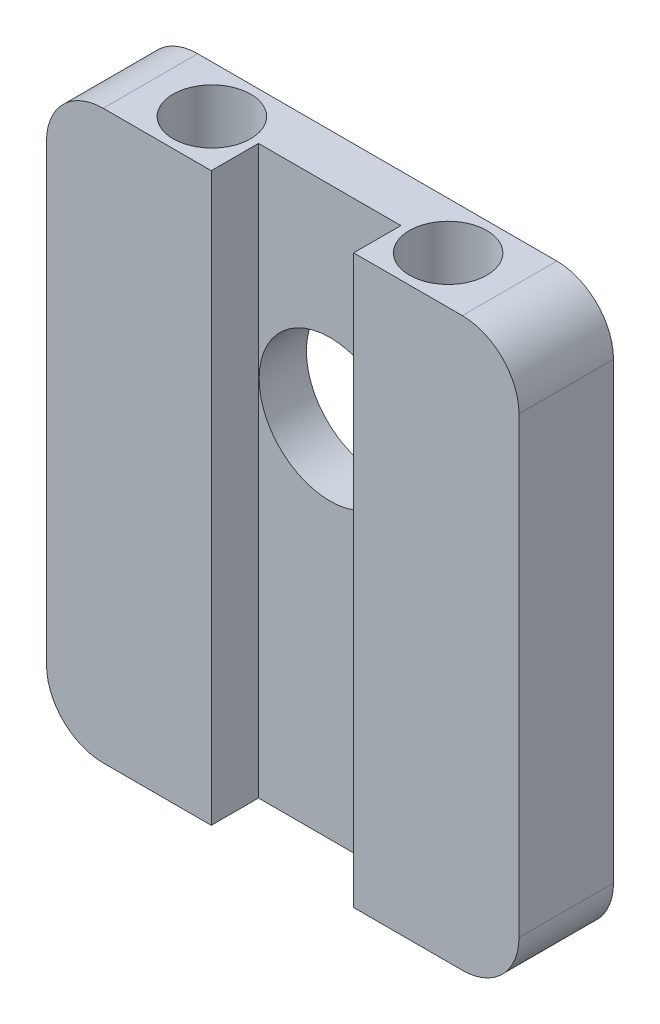
from build123d import *

# Parameters (mm, degrees)
SKETCH4_W           = 63.5
SKETCH4_H           = 12.7
BOSS_EXTRUDE1_DEPTH = 76.2
SKETCH5_R           = 5.207
CUT_EXTRUDE1_DEPTH  = 69.85
SKETCH7_W           = 19.133838299
SKETCH7_H           = 6.35
CUT_EXTRUDE2_DEPTH  = 77.2
SKETCH9_R           = 9.525
CUT_EXTRUDE3_DEPTH  = 13.7
FILLET2_R           = 7.62


with BuildPart() as part:
    # Sketch4 → Boss-Extrude1 (new body)
    with BuildSketch(Plane(origin=(0, 0, 0), x_dir=(1, 0, 0), z_dir=(0, 1, 0))):
        with Locations((31.75, 6.35)):
            Rectangle(SKETCH4_W, SKETCH4_H)
    extrude(amount=BOSS_EXTRUDE1_DEPTH)

    # Sketch5 → Cut-Extrude1 (cut)
    with BuildSketch(Plane(origin=(0, 76.2, 0), x_dir=(1, 0, 0), z_dir=(0, 1, 0))):
        with Locations((47.625, 6.35)):
            Circle(SKETCH5_R)
        with Locations((15.875, 6.35)):
            Circle(SKETCH5_R)
    extrude(amount=-CUT_EXTRUDE1_DEPTH, mode=Mode.SUBTRACT)

    # Sketch7 → Cut-Extrude2 (cut, through all)
    with BuildSketch(Plane(origin=(0, 76.2, 0), x_dir=(1, 0, 0), z_dir=(0, 1, 0))):
        with Locations((31.708080851, 3.175)):
            Rectangle(SKETCH7_W, SKETCH7_H)
    extrude(amount=-CUT_EXTRUDE2_DEPTH, mode=Mode.SUBTRACT)

    # Sketch9 → Cut-Extrude3 (cut, through all)
    with BuildSketch(Plane(origin=(0, 0, -12.7), x_dir=(-1, 0, 0), z_dir=(0, 0, -1))):
        with Locations((-31.75, 48.895)):
            Circle(SKETCH9_R)
    extrude(amount=-CUT_EXTRUDE3_DEPTH, mode=Mode.SUBTRACT)

    # Fillet2
    fillet2_edges = [part.edges().sort_by_distance(p)[0] for p in [
        (63.5, 76.2, -6.35),
        (0, 76.2, -6.35),
        (63.5, 0, -6.35),
        (0, 0, -6.35),
    ]]
    fillet(fillet2_edges, radius=FILLET2_R)


solid = part.part
